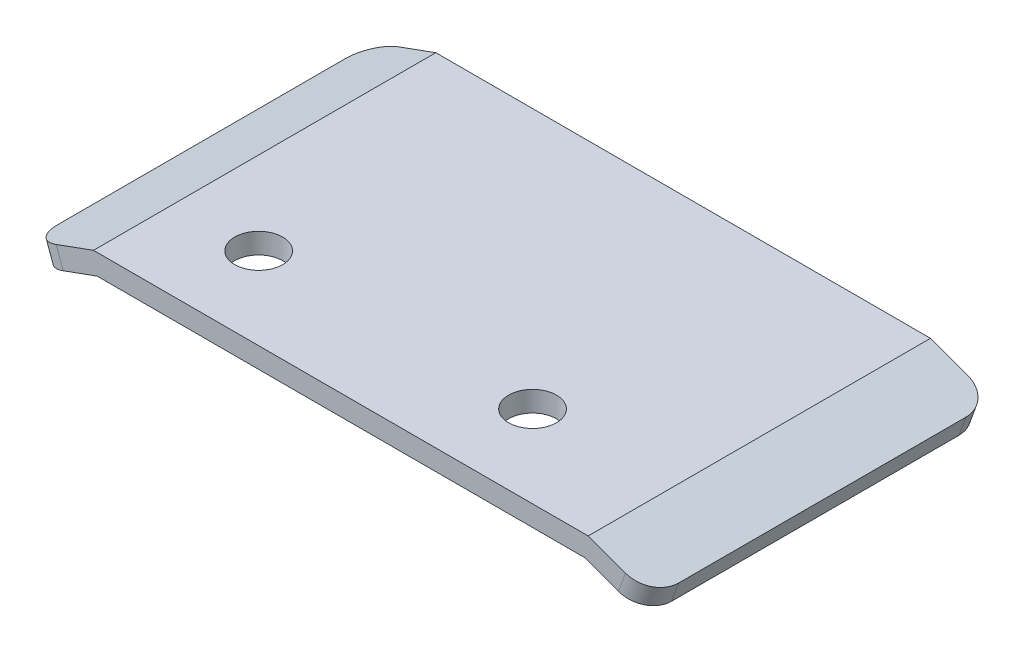
from build123d import *

# Parameters (mm, degrees)
BOSS_EXTRUDE1_DEPTH = 25
SKETCH2_R           = 1.75
CUT_EXTRUDE1_DEPTH  = 2.5
FILLET1_R           = 2


with BuildPart() as part:
    # Sketch1 → Boss-Extrude1 (new body)
    with BuildSketch(Plane.XY):
        Polygon((-19.601594954, 4.272951405), (-14.997101112, 5.948850108), (21.13187983, 5.948850108), (25.736373672, 4.272951405), (25.223343457, 2.863412474), (20.867389359, 4.448850108), (-14.732610641, 4.448850108), (-19.088564739, 2.863412474), align=None)
    extrude(amount=BOSS_EXTRUDE1_DEPTH)

    # Sketch2 → Cut-Extrude1 (cut, through all)
    with BuildSketch(Plane.XZ.offset(-4.448850108)):
        with Locations((-8.932610641, 19)):
            Circle(SKETCH2_R)
        with Locations((11.067389359, 19)):
            Circle(SKETCH2_R)
    extrude(amount=-CUT_EXTRUDE1_DEPTH, mode=Mode.SUBTRACT)

    # Fillet1
    fillet1_edges = [part.edges().sort_by_distance(p)[0] for p in [
        (-19.345079846, 3.56818194, 0),
        (25.479858564, 3.56818194, 25),
        (-19.345079846, 3.56818194, 25),
        (25.479858564, 3.56818194, 0),
    ]]
    fillet(fillet1_edges, radius=FILLET1_R)


solid = part.part
